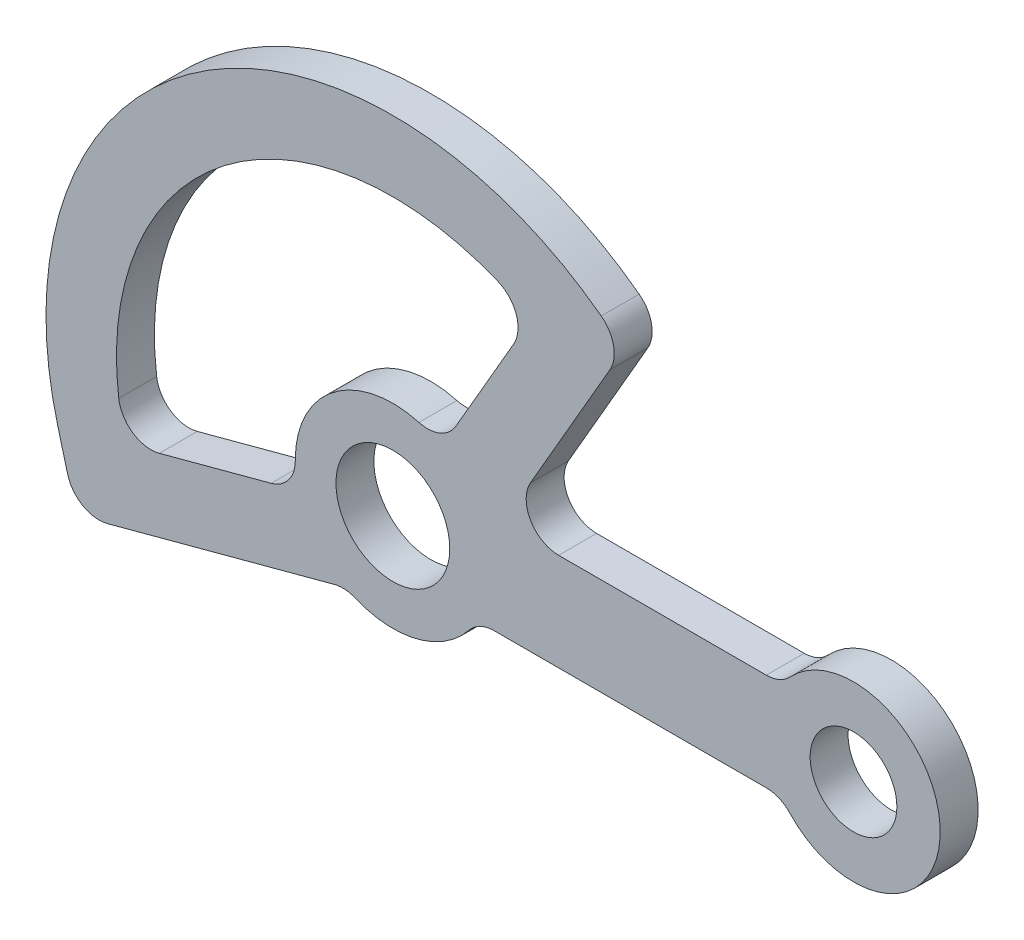
from build123d import *

# Parameters (mm, degrees)
SKETCH1_R           = 10.5
SKETCH1_R_2         = 8
BOSS_EXTRUDE1_DEPTH = 7


with BuildPart() as part:
    # Sketch1 → Boss-Extrude1 (new body)
    with BuildSketch(Plane.XY):
        with BuildLine():
            Line((25.403411844, 18), (40.04634859, 43.362310416))
            ThreePointArc((40.04634859, 43.362310416), (40.729032534, 47.562011618), (38.455388874, 51.158411493))
            ThreePointArc((38.455388874, 51.158411493), (-35.819868425, 53.037128749), (-61.819252882, -16.564418887))
            Line((-61.819252882, -16.564418887), (-60.007519567, -23.325899671))
            ThreePointArc((-60.007519567, -23.325899671), (-57.211964609, -26.969137823), (-52.659050338, -27.568540358))
            Line((-52.659050338, -27.568540358), (-10.79860525, -16.352067901))
            ThreePointArc((-10.79860525, -16.352067901), (-8.844993295, -16.161017697), (-6.934268235, -16.610717144))
            ThreePointArc((-6.934268235, -16.610717144), (4.455015534, -17.439978113), (14.051245496, -11.25))
            ThreePointArc((14.051245496, -11.25), (16.136917784, -9.591673087), (18.734993995, -9))
            Line((18.734993995, -9), (68.906523061, -9))
            ThreePointArc((68.906523061, -9), (71.299695166, -9.497934272), (73.295653135, -10.909090909))
            ThreePointArc((73.295653135, -10.909090909), (101, 0), (73.295653135, 10.909090909))
            ThreePointArc((73.295653135, 10.909090909), (71.299695166, 9.497934272), (68.906523061, 9))
            Line((68.906523061, 9), (30.599564267, 9))
            ThreePointArc((30.599564267, 9), (25.403411844, 12), (25.403411844, 18))
        make_face()
        Circle(SKETCH1_R, mode=Mode.SUBTRACT)
        with Locations((85, 0)):
            Circle(SKETCH1_R_2, mode=Mode.SUBTRACT)
        with BuildLine():
            Line((-22.446087833, -6.014411108), (-43.078559215, -11.542865153))
            ThreePointArc((-43.078559215, -11.542865153), (-47.971955445, -10.731402919), (-50.582336617, -6.513618221))
            ThreePointArc((-50.582336617, -6.513618221), (-31.046832879, 40.461020355), (19.383344125, 47.172936845))
            ThreePointArc((19.383344125, 47.172936845), (22.781794932, 43.559859246), (22.299103121, 38.623179569))
            Line((22.299103121, 38.623179569), (11.618950039, 20.124611797))
            ThreePointArc((11.618950039, 20.124611797), (8.69359949, 17.570923037), (4.817098212, 17.343458848))
            ThreePointArc((4.817098212, 17.343458848), (-10.957705722, 14.280360125), (-17.999251578, -0.164142113))
            ThreePointArc((-17.999251578, -0.164142113), (-19.222277472, -3.849682749), (-22.446087833, -6.014411108))
        make_face(mode=Mode.SUBTRACT)
    extrude(amount=BOSS_EXTRUDE1_DEPTH)


solid = part.part
